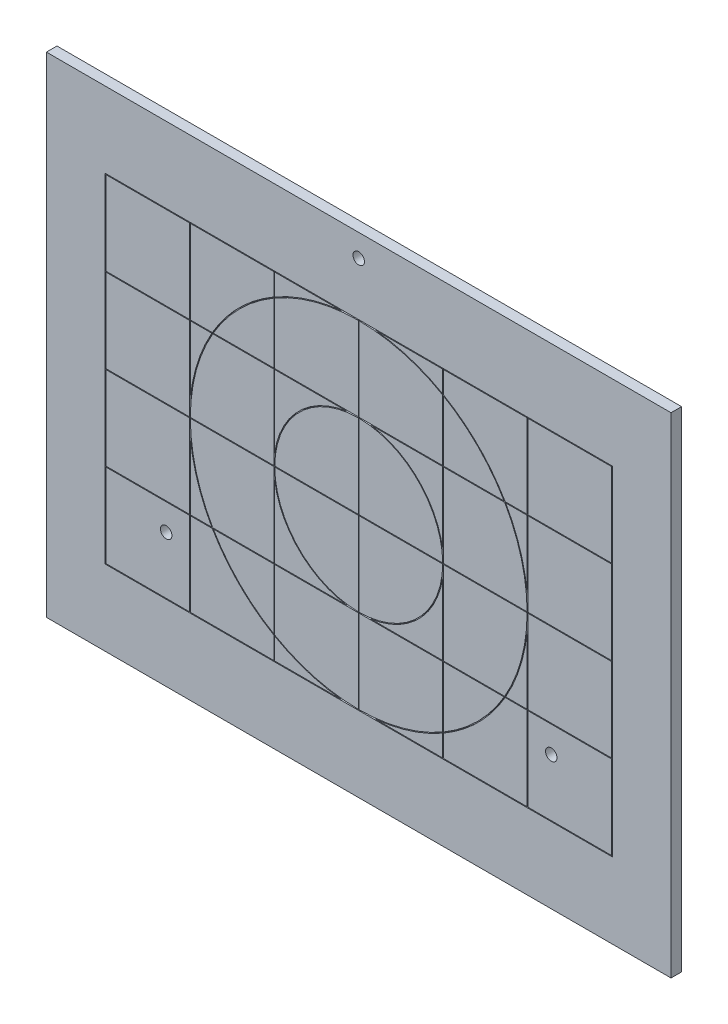
from build123d import *

# Parameters (mm, degrees)
SKETCH1_W             = 187.96
SKETCH1_H             = 147.32
SKETCH1_R             = 1.143
BOSS_EXTRUDE1_DEPTH   = 3.175
F_8_32_TAPPED_HOLE1_D = 3.4544
SKETCH4_W             = 25.146
SKETCH4_H             = 25.146
CUT_EXTRUDE1_DEPTH    = 0.508


with BuildPart() as part:
    # Sketch1 → Boss-Extrude1 (new body)
    with BuildSketch(Plane.XY):
        with Locations((57.93867, 33.450906721)):
            Rectangle(SKETCH1_W, SKETCH1_H)
        with Locations((57.93867, 100.352720163)):
            Circle(SKETCH1_R, mode=Mode.SUBTRACT)
        Circle(SKETCH1_R, mode=Mode.SUBTRACT)
        with Locations((115.87734, 0)):
            Circle(SKETCH1_R, mode=Mode.SUBTRACT)
    extrude(amount=BOSS_EXTRUDE1_DEPTH)

    # #8-32 Tapped Hole1 (through all)
    with Locations(Plane.XY.offset(3.175)):
        with Locations((57.93867, 100.352720163), (115.87734, 0), (0, 0)):
            Hole(F_8_32_TAPPED_HOLE1_D / 2)

    # Sketch4 → Cut-Extrude1 (cut)
    with BuildSketch(Plane.XY.offset(3.175)):
        Polygon((57.81167, 84.377906721), (-18.38833, 84.377906721), (-18.38833, -17.476093279), (134.26567, -17.476093279), (134.26567, 84.377906721), (58.06567, 84.377906721), align=None)
        with Locations((-5.56133, -4.649093279)):
            Rectangle(SKETCH4_W, SKETCH4_H, mode=Mode.SUBTRACT)
        with BuildLine():
            Line((52.85867, -17.222093279), (32.66567, -17.222093279))
            Line((32.66567, -17.222093279), (32.66567, -10.76260705))
            ThreePointArc((32.66567, -10.76260705), (42.422311122, -15.054783009), (52.85867, -17.222093279))
        make_face(mode=Mode.SUBTRACT)
        with BuildLine():
            ThreePointArc((13.871317005, 7.923906721), (21.927842955, -2.559920324), (32.41167, -10.616446274))
            Line((32.41167, -10.616446274), (32.41167, -17.222093279))
            Line((32.41167, -17.222093279), (7.26567, -17.222093279))
            Line((7.26567, -17.222093279), (7.26567, 7.923906721))
            Line((7.26567, 7.923906721), (13.871317005, 7.923906721))
        make_face(mode=Mode.SUBTRACT)
        with BuildLine():
            Line((14.165102633, 7.923906721), (32.41167, 7.923906721))
            Line((32.41167, 7.923906721), (32.41167, -10.322660646))
            ThreePointArc((32.41167, -10.322660646), (22.107448077, -2.380315202), (14.165102633, 7.923906721))
        make_face(mode=Mode.SUBTRACT)
        with BuildLine():
            Line((32.66567, -10.469799102), (32.66567, 7.923906721))
            Line((32.66567, 7.923906721), (57.81167, 7.923906721))
            Line((57.81167, 7.923906721), (57.81167, -17.221934131))
            ThreePointArc((57.81167, -17.221934131), (44.797595772, -15.488495576), (32.66567, -10.469799102))
        make_face(mode=Mode.SUBTRACT)
        with BuildLine():
            Line((13.725156229, 8.177906721), (7.26567, 8.177906721))
            Line((7.26567, 8.177906721), (7.26567, 28.370906721))
            ThreePointArc((7.26567, 28.370906721), (9.43298027, 17.934547843), (13.725156229, 8.177906721))
        make_face(mode=Mode.SUBTRACT)
        with Locations((-5.56133, 20.750906721)):
            Rectangle(SKETCH4_W, SKETCH4_H, mode=Mode.SUBTRACT)
        with BuildLine():
            Line((32.66567, 8.177906721), (32.66567, 29.858804273))
            ThreePointArc((32.66567, 29.858804273), (39.888355197, 15.400591918), (54.346567552, 8.177906721))
            Line((54.346567552, 8.177906721), (32.66567, 8.177906721))
        make_face(mode=Mode.SUBTRACT)
        with BuildLine():
            Line((7.265829148, 33.323906721), (32.41167, 33.323906721))
            Line((32.41167, 33.323906721), (32.41167, 8.177906721))
            Line((32.41167, 8.177906721), (14.017964177, 8.177906721))
            ThreePointArc((14.017964177, 8.177906721), (8.999267704, 20.309832493), (7.265829148, 33.323906721))
        make_face(mode=Mode.SUBTRACT)
        with BuildLine():
            ThreePointArc((57.81167, 8.178225818), (40.067960319, 15.58019704), (32.665989097, 33.323906721))
            Line((32.665989097, 33.323906721), (57.81167, 33.323906721))
            Line((57.81167, 33.323906721), (57.81167, 8.178225818))
        make_face(mode=Mode.SUBTRACT)
        with BuildLine():
            Line((83.21167, -17.222093279), (63.01867, -17.222093279))
            ThreePointArc((63.01867, -17.222093279), (73.455028878, -15.054783009), (83.21167, -10.76260705))
            Line((83.21167, -10.76260705), (83.21167, -17.222093279))
        make_face(mode=Mode.SUBTRACT)
        with BuildLine():
            ThreePointArc((83.21167, -10.469799102), (71.079744228, -15.488495576), (58.06567, -17.221934131))
            Line((58.06567, -17.221934131), (58.06567, 7.923906721))
            Line((58.06567, 7.923906721), (83.21167, 7.923906721))
            Line((83.21167, 7.923906721), (83.21167, -10.469799102))
        make_face(mode=Mode.SUBTRACT)
        with BuildLine():
            Line((108.61167, -17.222093279), (83.46567, -17.222093279))
            Line((83.46567, -17.222093279), (83.46567, -10.616446274))
            ThreePointArc((83.46567, -10.616446274), (93.949497045, -2.559920324), (102.006022995, 7.923906721))
            Line((102.006022995, 7.923906721), (108.61167, 7.923906721))
            Line((108.61167, 7.923906721), (108.61167, -17.222093279))
        make_face(mode=Mode.SUBTRACT)
        with BuildLine():
            Line((83.46567, -10.322660646), (83.46567, 7.923906721))
            Line((83.46567, 7.923906721), (101.712237367, 7.923906721))
            ThreePointArc((101.712237367, 7.923906721), (93.769891923, -2.380315202), (83.46567, -10.322660646))
        make_face(mode=Mode.SUBTRACT)
        with Locations((121.43867, -4.649093279)):
            Rectangle(SKETCH4_W, SKETCH4_H, mode=Mode.SUBTRACT)
        with BuildLine():
            ThreePointArc((61.530772448, 8.177906721), (75.988984803, 15.400591918), (83.21167, 29.858804273))
            Line((83.21167, 29.858804273), (83.21167, 8.177906721))
            Line((83.21167, 8.177906721), (61.530772448, 8.177906721))
        make_face(mode=Mode.SUBTRACT)
        with BuildLine():
            Line((58.06567, 8.178225818), (58.06567, 33.323906721))
            Line((58.06567, 33.323906721), (83.211350903, 33.323906721))
            ThreePointArc((83.211350903, 33.323906721), (75.809379681, 15.58019704), (58.06567, 8.178225818))
        make_face(mode=Mode.SUBTRACT)
        with BuildLine():
            Line((101.859375823, 8.177906721), (83.46567, 8.177906721))
            Line((83.46567, 8.177906721), (83.46567, 33.323906721))
            Line((83.46567, 33.323906721), (108.611510852, 33.323906721))
            ThreePointArc((108.611510852, 33.323906721), (106.878072296, 20.309832493), (101.859375823, 8.177906721))
        make_face(mode=Mode.SUBTRACT)
        with BuildLine():
            Line((108.61167, 8.177906721), (102.152183771, 8.177906721))
            ThreePointArc((102.152183771, 8.177906721), (106.44435973, 17.934547843), (108.61167, 28.370906721))
            Line((108.61167, 28.370906721), (108.61167, 8.177906721))
        make_face(mode=Mode.SUBTRACT)
        with Locations((121.43867, 20.750906721)):
            Rectangle(SKETCH4_W, SKETCH4_H, mode=Mode.SUBTRACT)
        with Locations((-5.56133, 46.150906721)):
            Rectangle(SKETCH4_W, SKETCH4_H, mode=Mode.SUBTRACT)
        with BuildLine():
            Line((7.26567, 38.530906721), (7.26567, 58.723906721))
            Line((7.26567, 58.723906721), (13.725156229, 58.723906721))
            ThreePointArc((13.725156229, 58.723906721), (9.43298027, 48.967265599), (7.26567, 38.530906721))
        make_face(mode=Mode.SUBTRACT)
        with BuildLine():
            Line((14.017964177, 58.723906721), (32.41167, 58.723906721))
            Line((32.41167, 58.723906721), (32.41167, 33.577906721))
            Line((32.41167, 33.577906721), (7.265829148, 33.577906721))
            ThreePointArc((7.265829148, 33.577906721), (8.999267704, 46.591980949), (14.017964177, 58.723906721))
        make_face(mode=Mode.SUBTRACT)
        with BuildLine():
            Line((57.81167, 33.577906721), (32.665989097, 33.577906721))
            ThreePointArc((32.665989097, 33.577906721), (40.067960319, 51.321616402), (57.81167, 58.723587623))
            Line((57.81167, 58.723587623), (57.81167, 33.577906721))
        make_face(mode=Mode.SUBTRACT)
        with BuildLine():
            Line((32.66567, 37.043009169), (32.66567, 58.723906721))
            Line((32.66567, 58.723906721), (54.346567552, 58.723906721))
            ThreePointArc((54.346567552, 58.723906721), (39.888355197, 51.501221524), (32.66567, 37.043009169))
        make_face(mode=Mode.SUBTRACT)
        with Locations((-5.56133, 71.550906721)):
            Rectangle(SKETCH4_W, SKETCH4_H, mode=Mode.SUBTRACT)
        with BuildLine():
            Line((32.41167, 58.977906721), (14.165102633, 58.977906721))
            ThreePointArc((14.165102633, 58.977906721), (22.107448077, 69.282128644), (32.41167, 77.224474088))
            Line((32.41167, 77.224474088), (32.41167, 58.977906721))
        make_face(mode=Mode.SUBTRACT)
        with BuildLine():
            Line((7.26567, 84.123906721), (32.41167, 84.123906721))
            Line((32.41167, 84.123906721), (32.41167, 77.518259716))
            ThreePointArc((32.41167, 77.518259716), (21.927842955, 69.461733766), (13.871317005, 58.977906721))
            Line((13.871317005, 58.977906721), (7.26567, 58.977906721))
            Line((7.26567, 58.977906721), (7.26567, 84.123906721))
        make_face(mode=Mode.SUBTRACT)
        with BuildLine():
            Line((57.81167, 84.123747573), (57.81167, 58.977906721))
            Line((57.81167, 58.977906721), (32.66567, 58.977906721))
            Line((32.66567, 58.977906721), (32.66567, 77.371612544))
            ThreePointArc((32.66567, 77.371612544), (44.797595772, 82.390309017), (57.81167, 84.123747573))
        make_face(mode=Mode.SUBTRACT)
        with BuildLine():
            Line((32.66567, 77.664420492), (32.66567, 84.123906721))
            Line((32.66567, 84.123906721), (52.85867, 84.123906721))
            ThreePointArc((52.85867, 84.123906721), (42.422311122, 81.956596451), (32.66567, 77.664420492))
        make_face(mode=Mode.SUBTRACT)
        with BuildLine():
            Line((83.211350903, 33.577906721), (58.06567, 33.577906721))
            Line((58.06567, 33.577906721), (58.06567, 58.723587623))
            ThreePointArc((58.06567, 58.723587623), (75.809379681, 51.321616402), (83.211350903, 33.577906721))
        make_face(mode=Mode.SUBTRACT)
        with BuildLine():
            Line((83.46567, 33.577906721), (83.46567, 58.723906721))
            Line((83.46567, 58.723906721), (101.859375823, 58.723906721))
            ThreePointArc((101.859375823, 58.723906721), (106.878072296, 46.591980949), (108.611510852, 33.577906721))
            Line((108.611510852, 33.577906721), (83.46567, 33.577906721))
        make_face(mode=Mode.SUBTRACT)
        with BuildLine():
            Line((61.530772448, 58.723906721), (83.21167, 58.723906721))
            Line((83.21167, 58.723906721), (83.21167, 37.043009169))
            ThreePointArc((83.21167, 37.043009169), (75.988984803, 51.501221524), (61.530772448, 58.723906721))
        make_face(mode=Mode.SUBTRACT)
        with Locations((121.43867, 46.150906721)):
            Rectangle(SKETCH4_W, SKETCH4_H, mode=Mode.SUBTRACT)
        with BuildLine():
            ThreePointArc((108.61167, 38.530906721), (106.44435973, 48.967265599), (102.152183771, 58.723906721))
            Line((102.152183771, 58.723906721), (108.61167, 58.723906721))
            Line((108.61167, 58.723906721), (108.61167, 38.530906721))
        make_face(mode=Mode.SUBTRACT)
        with BuildLine():
            ThreePointArc((58.06567, 84.123747573), (71.079744228, 82.390309017), (83.21167, 77.371612544))
            Line((83.21167, 77.371612544), (83.21167, 58.977906721))
            Line((83.21167, 58.977906721), (58.06567, 58.977906721))
            Line((58.06567, 58.977906721), (58.06567, 84.123747573))
        make_face(mode=Mode.SUBTRACT)
        with BuildLine():
            Line((83.46567, 58.977906721), (83.46567, 77.224474088))
            ThreePointArc((83.46567, 77.224474088), (93.769891923, 69.282128644), (101.712237367, 58.977906721))
            Line((101.712237367, 58.977906721), (83.46567, 58.977906721))
        make_face(mode=Mode.SUBTRACT)
        with BuildLine():
            Line((83.46567, 77.518259716), (83.46567, 84.123906721))
            Line((83.46567, 84.123906721), (108.61167, 84.123906721))
            Line((108.61167, 84.123906721), (108.61167, 58.977906721))
            Line((108.61167, 58.977906721), (102.006022995, 58.977906721))
            ThreePointArc((102.006022995, 58.977906721), (93.949497045, 69.461733766), (83.46567, 77.518259716))
        make_face(mode=Mode.SUBTRACT)
        with BuildLine():
            Line((63.01867, 84.123906721), (83.21167, 84.123906721))
            Line((83.21167, 84.123906721), (83.21167, 77.664420492))
            ThreePointArc((83.21167, 77.664420492), (73.455028878, 81.956596451), (63.01867, 84.123906721))
        make_face(mode=Mode.SUBTRACT)
        with Locations((121.43867, 71.550906721)):
            Rectangle(SKETCH4_W, SKETCH4_H, mode=Mode.SUBTRACT)
    extrude(amount=-CUT_EXTRUDE1_DEPTH, mode=Mode.SUBTRACT)


solid = part.part
